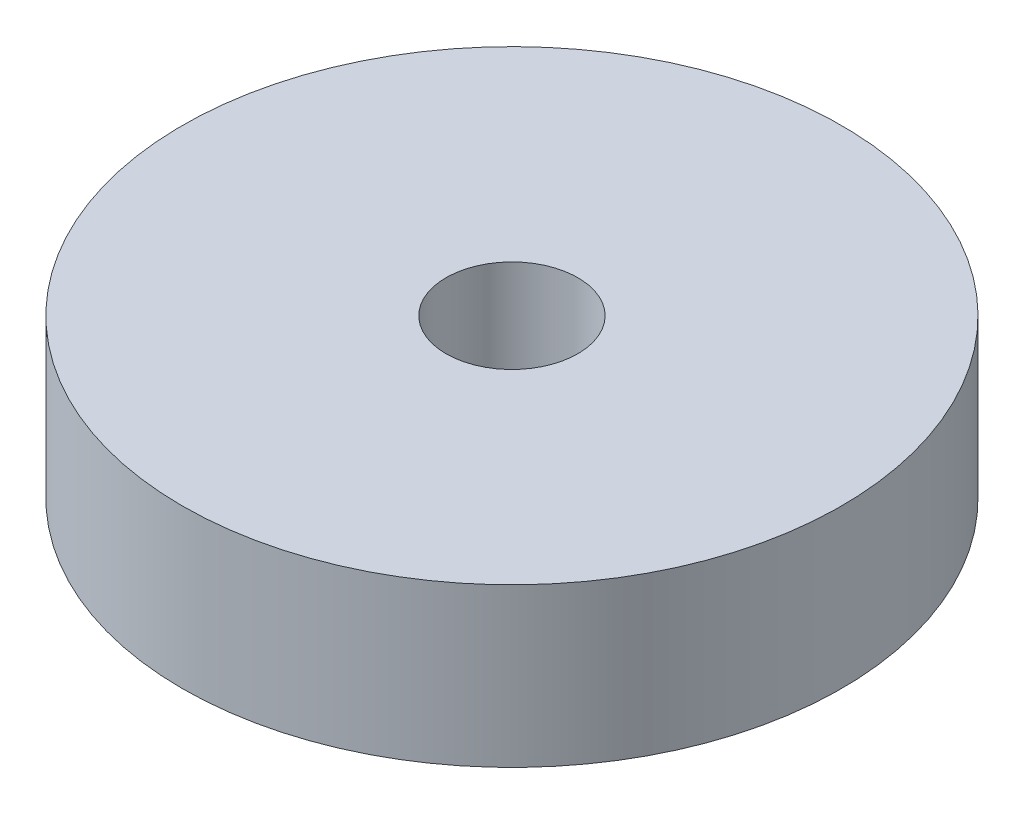
from build123d import *

# Parameters (mm, degrees)
SKETCH_1_R      = 12.5
SKETCH_1_R_2    = 2.5
EXTRUDE_1_DEPTH = 6


with BuildPart() as part:
    # 草图1 → 凸台-拉伸1 (new body)
    with BuildSketch(Plane(origin=(0, 0, 0), x_dir=(1, 0, 0), z_dir=(0, 1, 0))):
        Circle(SKETCH_1_R)
        Circle(SKETCH_1_R_2, mode=Mode.SUBTRACT)
    extrude(amount=EXTRUDE_1_DEPTH)


solid = part.part
